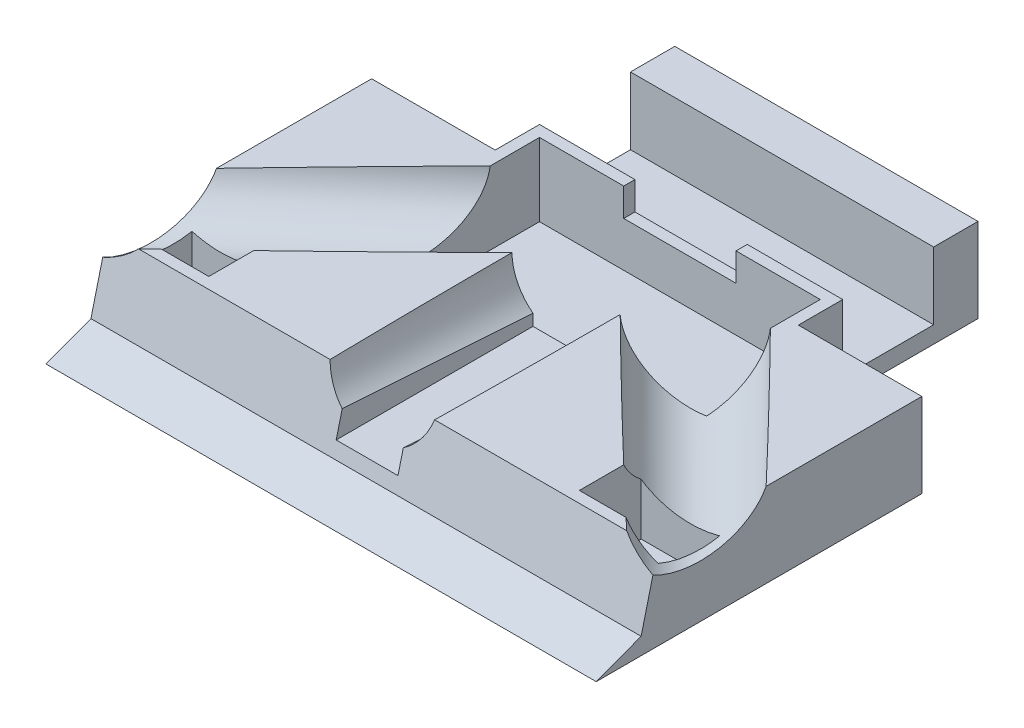
from build123d import *

# Parameters (mm, degrees)
SKETCH1_W                = 98
SKETCH1_H                = 90
BOSS_EXTRUDE1_DEPTH      = 15
CUT_EXTRUDE1_DEPTH       = 15
CUT_EXTRUDE2_DEPTH       = 15
CUT_EXTRUDE5_DEPTH       = 100
CUT_EXTRUDE6_DEPTH       = 100
SKETCH9_R                = 9.5
CUT_EXTRUDE7_DEPTH       = 45
SKETCH10_R               = 9.5
CUT_EXTRUDE8_DEPTH       = 45
BOSS_EXTRUDE3_DEPTH      = 100
BOSS_EXTRUDE4_DEPTH      = 100
SKETCH14_W               = 54.537944566
SKETCH14_H               = 37.433727788
CUT_EXTRUDE9_DEPTH       = 100
SKETCH15_W               = 37.221464136
SKETCH15_H               = 31.979004399
CUT_EXTRUDE10_DEPTH      = 100
BOSS_EXTRUDE5_DEPTH      = 15
BOSS_EXTRUDE6_DEPTH      = 15
BOSS_EXTRUDE7_DEPTH      = 15
CUT_EXTRUDE11_DEPTH      = 100
SKETCH20_R               = 9.5
CUT_EXTRUDE12_DEPTH      = 45
SKETCH21_R               = 9.5
CUT_EXTRUDE13_DEPTH      = 100
SKETCH22_R               = 9.5
BOSS_EXTRUDE8_DEPTH      = 55
SKETCH23_R               = 9.5
CUT_EXTRUDE14_DEPTH      = 55
SKETCH24_R               = 9.5
CUT_EXTRUDE15_DEPTH      = 100
SKETCH25_R               = 9.5
BOSS_EXTRUDE10_DEPTH     = 100
SKETCH26_R               = 9.5
CUT_EXTRUDE16_DEPTH      = 100
CUT_EXTRUDE19_DEPTH      = 100
CUT_EXTRUDE19_DEPTH_BACK = 100
SKETCH27_W               = 176.377882562
SKETCH27_H               = 122.842530298
SKETCH27_W_2             = 98
SKETCH27_H_2             = 90
SKETCH28_W               = 109.510814303
SKETCH28_H               = 24.111992001
CUT_EXTRUDE20_DEPTH      = 100
SKETCH29_R               = 9.59940523
CUT_EXTRUDE21_DEPTH      = 100
SKETCH30_W               = 22
SKETCH30_H               = 32
CUT_EXTRUDE22_DEPTH      = 100
SKETCH31_W               = 16.2
SKETCH31_H               = 12
CUT_EXTRUDE23_DEPTH      = 100
CUT_EXTRUDE24_DEPTH      = 13
SKETCH33_W               = 50.373016546
SKETCH33_H               = 2
BOSS_EXTRUDE12_DEPTH     = 15
SKETCH34_W               = 20
SKETCH34_H               = 2
CUT_EXTRUDE25_DEPTH      = 5
CUT_EXTRUDE27_DEPTH      = 100
SKETCH37_W               = 14
SKETCH37_H               = 11
CUT_EXTRUDE28_DEPTH      = 13
CUT_EXTRUDE32_DEPTH      = 9.5


with BuildPart() as part:
    # Sketch1 → Boss-Extrude1 (new body)
    with BuildSketch(Plane(origin=(0, 0, 0), x_dir=(1, 0, 0), z_dir=(0, 1, 0))):
        with Locations((7.915679061, -25.165675541)):
            Rectangle(SKETCH1_W, SKETCH1_H)
    extrude(amount=BOSS_EXTRUDE1_DEPTH)

    # Sketch3 → Cut-Extrude1 (cut)
    with BuildSketch(Plane(origin=(0, 15, 0), x_dir=(1, 0, 0), z_dir=(0, 1, 0))):
        Polygon((-41.084320939, -35.165675541), (-6.084320939, -70.165675541), (-41.084320939, -70.165675541), align=None)
        Polygon((21.915679061, -70.165675541), (56.915679061, -35.165675541), (56.915679061, -70.165675541), align=None)
    extrude(amount=-CUT_EXTRUDE1_DEPTH, mode=Mode.SUBTRACT)

    # Sketch4 → Cut-Extrude2 (cut)
    with BuildSketch(Plane(origin=(0, 15, 0), x_dir=(1, 0, 0), z_dir=(0, 1, 0))):
        Polygon((-41.084320939, -35.165675541), (-32.241899351, -26.323253953), (-41.084320939, -17.480832365), align=None)
        Polygon((56.915679061, -17.480832365), (48.073257473, -26.323253953), (56.915679061, -35.165675541), align=None)
    extrude(amount=-CUT_EXTRUDE2_DEPTH, mode=Mode.SUBTRACT)

    # Sketch5 → Cut-Extrude5 (cut)
    with BuildSketch(Plane(origin=(-2.959322699, 0, -2.959322699), x_dir=(-0.7071067811865461, 0, 0.7071067811865489), z_dir=(-0.7071067811865489, 0, -0.7071067811865461))):
        Polygon((53.916889577, 0), (52.916889577, 15), (53.916889577, 15), align=None)
    extrude(amount=-CUT_EXTRUDE5_DEPTH, mode=Mode.SUBTRACT)

    # Sketch8 → Cut-Extrude6 (cut)
    with BuildSketch(Plane(origin=(10.87500176, 0, -10.87500176), x_dir=(-0.7071067811865438, 0, -0.7071067811865513), z_dir=(0.7071067811865513, 0, -0.7071067811865438))):
        Polygon((-65.11135026, 0), (-64.11135026, 15), (-65.11135026, 15), align=None)
    extrude(amount=-CUT_EXTRUDE6_DEPTH, mode=Mode.SUBTRACT)

    # Sketch9 → Cut-Extrude7 (cut)
    with BuildSketch(Plane(origin=(45.83695749, 4.321549796, 45.83695749), x_dir=(0.7086694500121591, -0.06622532692378834, -0.7024256663116043), z_dir=(0.7055406512876944, 0.06651901052377404, 0.7055406512877016))):
        with Locations((-0.364665022, 13.674807707)):
            Circle(SKETCH9_R)
    extrude(amount=-CUT_EXTRUDE7_DEPTH, mode=Mode.SUBTRACT)

    # Sketch10 → Cut-Extrude8 (cut)
    with BuildSketch(Plane(origin=(-37.956303558, 3.578554618, 37.956303558), x_dir=(0.708669450012157, 0.06622532692378813, 0.7024256663116066), z_dir=(-0.7055406512876966, 0.06651901052377338, 0.7055406512876994))):
        with Locations((11.452044949, 13.683576238)):
            Circle(SKETCH10_R)
    extrude(amount=-CUT_EXTRUDE8_DEPTH, mode=Mode.SUBTRACT)

    # Sketch12 → Boss-Extrude3 (add)
    with BuildSketch(Plane(origin=(10.87500176, 0, -10.87500176), x_dir=(-0.7071067811865438, 0, -0.7071067811865513), z_dir=(0.7071067811865513, 0, -0.7071067811865438))):
        Polygon((-65.11135026, 0), (-64.11135026, 15), (-65.11135026, 15), align=None)
    extrude(amount=-BOSS_EXTRUDE3_DEPTH)

    # Sketch13 → Boss-Extrude4 (add)
    with BuildSketch(Plane(origin=(-2.959322699, 0, -2.959322699), x_dir=(-0.7071067811865461, 0, 0.7071067811865489), z_dir=(-0.7071067811865489, 0, -0.7071067811865461))):
        Polygon((53.916889577, 0), (52.916889577, 15), (53.916889577, 15), align=None)
    extrude(amount=-BOSS_EXTRUDE4_DEPTH)

    # Sketch14 → Cut-Extrude9 (cut)
    with BuildSketch(Plane(origin=(0, 15, 0), x_dir=(1, 0, 0), z_dir=(0, 1, 0))):
        with Locations((21.184651344, -88.882539435)):
            Rectangle(SKETCH14_W, SKETCH14_H)
    extrude(amount=-CUT_EXTRUDE9_DEPTH, mode=Mode.SUBTRACT)


with BuildPart() as cut_extrude9_piece_1:
    # of the separate pieces the step leaves, piece 1, a body of its own (cut_extrude9_pieces)
    add(part.part.solids().sort_by_distance((-41.084320939, 0, -19.834324459))[0])

    # Sketch16 → Boss-Extrude5 (add)
    with BuildSketch(Plane(origin=(0, 15, 0), x_dir=(1, 0, 0), z_dir=(0, 1, 0))):
        Polygon((-6.084320939, -70.165675541), (-35.8985557, -70.165675541), (-41.084320939, -70.165675541), (-41.084320939, -35.165675541), align=None)
    extrude(amount=-BOSS_EXTRUDE5_DEPTH)

    # Sketch17 → Boss-Extrude6 (add)
    with BuildSketch(Plane(origin=(0, 15, 0), x_dir=(1, 0, 0), z_dir=(0, 1, 0))):
        Polygon((21.915679061, -70.165675541), (49.886241171, -70.165675541), (56.915679061, -70.165675541), (56.915679061, -35.165675541), align=None)
    extrude(amount=-BOSS_EXTRUDE6_DEPTH)

    # Sketch18 → Boss-Extrude7 (add)
    with BuildSketch(Plane(origin=(0, 15, 0), x_dir=(1, 0, 0), z_dir=(0, 1, 0))):
        Polygon((48.073257473, -26.323253953), (56.915679061, -17.480832365), (56.915679061, -35.165675541), align=None)
        Polygon((-41.084320939, -35.165675541), (-41.084320939, -17.480832365), (-32.241899351, -26.323253953), align=None)
    extrude(amount=-BOSS_EXTRUDE7_DEPTH)

    # Sketch19 → Cut-Extrude11 (cut)
    with BuildSketch(Plane(origin=(56.915679061, 0, 0), x_dir=(0, 0, -1), z_dir=(1, 0, 0))):
        Polygon((-70.165675541, 0), (-69.165675541, 15), (-70.165675541, 15), align=None)
    extrude(amount=-CUT_EXTRUDE11_DEPTH, mode=Mode.SUBTRACT)

    # Sketch20 → Cut-Extrude12 (cut)
    with BuildSketch(Plane(origin=(0, 4.657013863, 69.85520795), x_dir=(1, 0, 0), z_dir=(0, 0.06651901052377399, 0.997785157856609))):
        with Locations((7.915679061, 13.33264869)):
            Circle(SKETCH20_R)
    extrude(amount=-CUT_EXTRUDE12_DEPTH, mode=Mode.SUBTRACT)

    # Sketch21 → Cut-Extrude13 (cut)
    with BuildSketch(Plane(origin=(14.087628182, 1.328194322, 14.087628182), x_dir=(0.708669450012159, -0.06622532692378837, -0.7024256663116044), z_dir=(0.7055406512876945, 0.06651901052377404, 0.7055406512877015))):
        with Locations((2.201455665, 13.878873478)):
            Circle(SKETCH21_R)
    extrude(amount=CUT_EXTRUDE13_DEPTH, mode=Mode.SUBTRACT)

    # Sketch22 → Boss-Extrude8 (add)
    with BuildSketch(Plane(origin=(14.087628182, 1.328194322, 14.087628182), x_dir=(0.708669450012159, -0.06622532692378837, -0.7024256663116044), z_dir=(0.7055406512876945, 0.06651901052377404, 0.7055406512877015))):
        with Locations((-0.364665022, 13.674807707)):
            Circle(SKETCH22_R)
    extrude(amount=BOSS_EXTRUDE8_DEPTH)

    # Sketch23 → Cut-Extrude14 (cut)
    with BuildSketch(Plane(origin=(52.892364003, 4.986739901, 52.892364003), x_dir=(0.7024256663116113, 0.0662253269237897, -0.7086694500121521), z_dir=(0.7055406512876945, 0.06651901052377404, 0.7055406512877014))):
        with Locations((4.020343442, 13.465005557)):
            Circle(SKETCH23_R)
    extrude(amount=-CUT_EXTRUDE14_DEPTH, mode=Mode.SUBTRACT)

    # Sketch24 → Cut-Extrude15 (cut)
    with BuildSketch(Plane(origin=(-6.20697425, 0.585199144, 6.20697425), x_dir=(0.708669450012157, 0.06622532692378813, 0.7024256663116066), z_dir=(-0.7055406512876966, 0.06651901052377338, 0.7055406512876995))):
        with Locations((8.951834225, 13.883257743)):
            Circle(SKETCH24_R)
    extrude(amount=CUT_EXTRUDE15_DEPTH, mode=Mode.SUBTRACT)

    # Sketch25 → Boss-Extrude10 (add)
    with BuildSketch(Plane(origin=(-6.20697425, 0.585199144, 6.20697425), x_dir=(0.708669450012157, 0.06622532692378813, 0.7024256663116066), z_dir=(-0.7055406512876966, 0.06651901052377338, 0.7055406512876994))):
        with Locations((11.452044949, 13.683576238)):
            Circle(SKETCH25_R)
    extrude(amount=BOSS_EXTRUDE10_DEPTH)

    # Sketch26 → Cut-Extrude16 (cut)
    with BuildSketch(Plane(origin=(-6.20697425, 0.585199144, 6.20697425), x_dir=(0.708669450012157, 0.06622532692378813, 0.7024256663116066), z_dir=(-0.7055406512876966, 0.06651901052377338, 0.7055406512876994))):
        with Locations((8.951834225, 13.883257743)):
            Circle(SKETCH26_R)
    extrude(amount=CUT_EXTRUDE16_DEPTH, mode=Mode.SUBTRACT)

    # Sketch27 → Cut-Extrude19 (cut, two sides: drawn at the far end of the back side and taken through both)
    with BuildSketch(Plane(origin=(0, 15, 0), x_dir=(1, 0, 0), z_dir=(0, 1, 0)).offset(-CUT_EXTRUDE19_DEPTH_BACK)):
        with Locations((3.867081439, -38.319377922)):
            Rectangle(SKETCH27_W, SKETCH27_H)
        with Locations((7.915679061, -25.165675541)):
            Rectangle(SKETCH27_W_2, SKETCH27_H_2, mode=Mode.SUBTRACT)
    extrude(amount=CUT_EXTRUDE19_DEPTH + CUT_EXTRUDE19_DEPTH_BACK, mode=Mode.SUBTRACT)

    # Sketch28 → Cut-Extrude20 (cut)
    with BuildSketch(Plane(origin=(0, 0, -19.834324459), x_dir=(-1, 0, 0), z_dir=(0, 0, -1))):
        with Locations((-2.16027191, 27.055996001)):
            Rectangle(SKETCH28_W, SKETCH28_H)
    extrude(amount=-CUT_EXTRUDE20_DEPTH, mode=Mode.SUBTRACT)

    # Sketch29 → Cut-Extrude21 (cut)
    with BuildSketch(Plane(origin=(0, 1.66365839, 24.954875847), x_dir=(1, 0, 0), z_dir=(0, 0.066519010523774, 0.997785157856609))):
        with Locations((7.822016096, 13.365945069)):
            Circle(SKETCH29_R)
    extrude(amount=CUT_EXTRUDE21_DEPTH, mode=Mode.SUBTRACT)

    # Sketch30 → Cut-Extrude22 (cut)
    with BuildSketch(Plane(origin=(0, 15, 0), x_dir=(1, 0, 0), z_dir=(0, 1, 0))):
        with Locations((-30.084320939, 3.834324459)):
            Rectangle(SKETCH30_W, SKETCH30_H)
        with Locations((45.915679061, 3.834324459)):
            Rectangle(SKETCH30_W, SKETCH30_H)
    extrude(amount=-CUT_EXTRUDE22_DEPTH, mode=Mode.SUBTRACT)

    # Sketch31 → Cut-Extrude23 (cut)
    with BuildSketch(Plane(origin=(34.915679061, 0, 0), x_dir=(0, 0, -1), z_dir=(1, 0, 0))):
        with Locations((3.834324459, 9)):
            Rectangle(SKETCH31_W, SKETCH31_H)
    extrude(amount=-CUT_EXTRUDE23_DEPTH, mode=Mode.SUBTRACT)

    # Sketch32 → Cut-Extrude24 (cut)
    with BuildSketch(Plane(origin=(0, 15, 0), x_dir=(1, 0, 0), z_dir=(0, 1, 0))):
        Polygon((-1.776033561, -26.490930679), (32.915679061, -26.490930679), (32.915679061, -6.265675541), (-1.776033561, -6.265675541), (-17.084320939, -6.265675541), (-17.084320939, -26.490930679), align=None)
    extrude(amount=-CUT_EXTRUDE24_DEPTH, mode=Mode.SUBTRACT)

    # Sketch33 → Boss-Extrude12 (add)
    with BuildSketch(Plane(origin=(0, 15, 0), x_dir=(1, 0, 0), z_dir=(0, 1, 0))):
        with Locations((7.729170788, -5.265675541)):
            Rectangle(SKETCH33_W, SKETCH33_H)
    extrude(amount=-BOSS_EXTRUDE12_DEPTH)

    # Sketch34 → Cut-Extrude25 (cut)
    with BuildSketch(Plane(origin=(0, 15, 0), x_dir=(1, 0, 0), z_dir=(0, 1, 0))):
        with Locations((7.915679061, -5.265675541)):
            Rectangle(SKETCH34_W, SKETCH34_H)
    extrude(amount=-CUT_EXTRUDE25_DEPTH, mode=Mode.SUBTRACT)

    # Sketch35 → Cut-Extrude27 (cut)
    with BuildSketch(Plane(origin=(56.915679061, 0, 0), x_dir=(0, 0, -1), z_dir=(1, 0, 0))):
        Polygon((-70.165675541, 0), (-62.165675541, 3), (-59.165675541, 15), (-69.165675541, 15), align=None)
    extrude(amount=-CUT_EXTRUDE27_DEPTH, mode=Mode.SUBTRACT)

    # Sketch37 → Cut-Extrude28 (cut)
    with BuildSketch(Plane(origin=(0, 15, 0), x_dir=(1, 0, 0), z_dir=(0, 1, 0))):
        with Locations((-32.084320939, -51.665675541)):
            Rectangle(SKETCH37_W, SKETCH37_H)
        with Locations((47.915679061, -51.665675541)):
            Rectangle(SKETCH37_W, SKETCH37_H)
    extrude(amount=-CUT_EXTRUDE28_DEPTH, mode=Mode.SUBTRACT)

    # Sketch38 → Cut-Extrude32 (cut)
    with BuildSketch(Plane(origin=(0, 15, 0), x_dir=(1, 0, 0), z_dir=(0, 1, 0))):
        Polygon((1.978443982, -26.490930679), (12.978443982, -26.490930679), (12.978443982, -60.585728785), (12.978443982, -67.440751443), (1.978443982, -67.440751443), (1.978443982, -60.585728785), align=None)
    extrude(amount=-CUT_EXTRUDE32_DEPTH, mode=Mode.SUBTRACT)


with BuildPart() as cut_extrude9_piece_2:
    # of the separate pieces the step leaves, piece 2, a body of its own (cut_extrude9_pieces)
    add(part.part.solids().sort_by_distance((-6.084320939, 15, 96.751461979))[0])

    # Sketch15 → Cut-Extrude10 (cut)
    with BuildSketch(Plane(origin=(0, 15, 0), x_dir=(1, 0, 0), z_dir=(0, 1, 0))):
        with Locations((-15.067513526, -92.658393077)):
            Rectangle(SKETCH15_W, SKETCH15_H)
    extrude(amount=-CUT_EXTRUDE10_DEPTH, mode=Mode.SUBTRACT)


solid = cut_extrude9_piece_1.part
